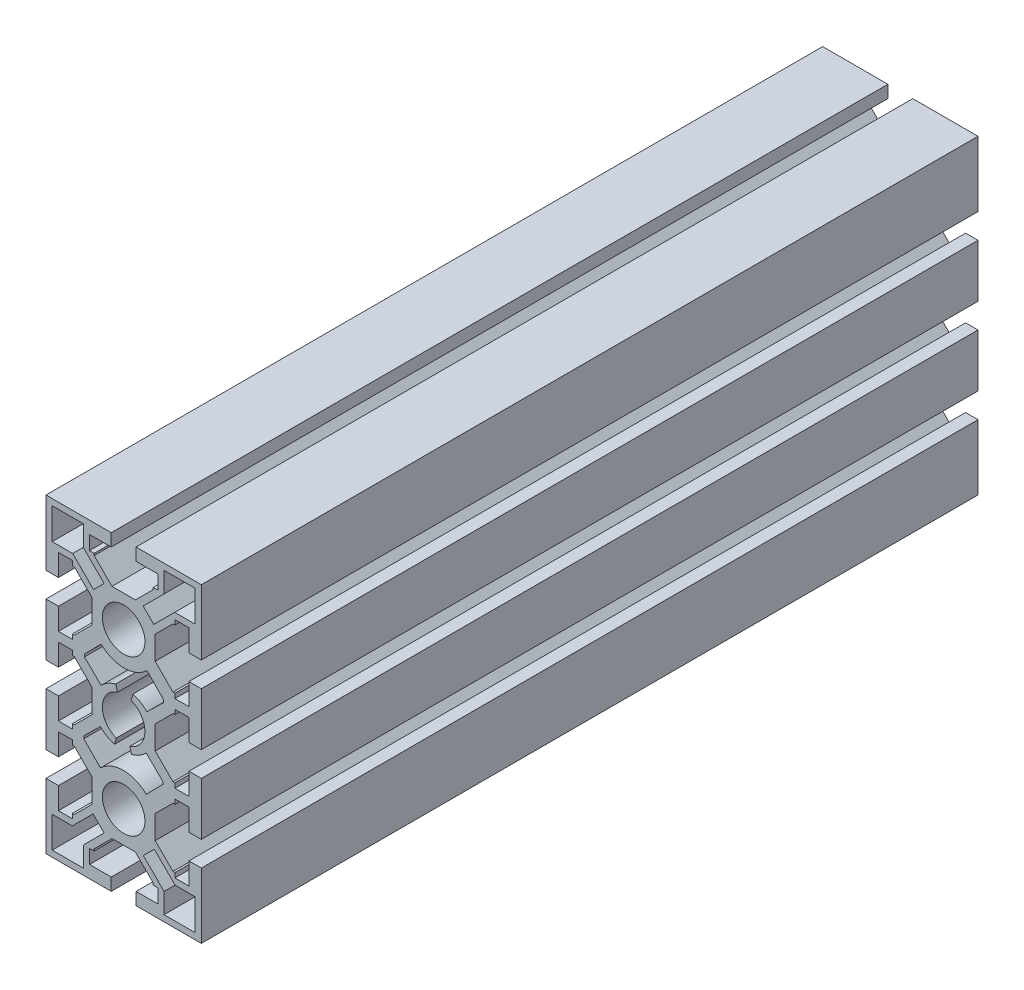
from build123d import *

# Parameters (mm, degrees)
SKETCH_A01_2_R     = 6.849979581
SKETCH_A01_2_R_2   = 6.85
SKETCH_A01_2_W     = 10
SKETCH_A01_2_H     = 10
EXTRUDE1_DEPTH     = 250
CUT_EXTRUDE1_DEPTH = 251
CIRPATTERN1_COUNT  = 2
CUT_EXTRUDE2_DEPTH = 251
CUT_EXTRUDE3_DEPTH = 251
CIRPATTERN2_COUNT  = 2
CIRPATTERN2_ANGLE  = 270
CIRPATTERN3_COUNT  = 2
CIRPATTERN3_ANGLE  = 90


with BuildPart() as part:
    # Sketch A01-2 → Extrude1 (new body)
    with BuildSketch(Plane.XY):
        Polygon((-16.5, -36), (-16.5, -34.5), (-15.863961, -34.5), (-10.14602885, -28.78206785), (-10.14602885, -21.21793215), (-15.863961, -15.5), (-16.5, -15.5), (-16.5, -14), (-21, -14), (-21, -21), (-25, -21), (-25, -4), (-21, -4), (-21, -11), (-16.5, -11), (-16.5, -9.5), (-15.863961, -9.5), (-10.14602885, -3.78206785), (-10.14602885, 3.78206785), (-15.863961, 9.5), (-16.5, 9.5), (-16.5, 11), (-21, 11), (-21, 4), (-25, 4), (-25, 21), (-21, 21), (-21, 14), (-16.5, 14), (-16.5, 15.5), (-15.863961, 15.5), (-10.14602885, 21.21793215), (-10.14602885, 28.78206785), (-15.863961, 34.5), (-16.5, 34.5), (-16.5, 36), (-21, 36), (-21, 29), (-25, 29), (-25, 50), (-4, 50), (-4, 46), (-11, 46), (-11, 41.5), (-9.5, 41.5), (-9.5, 40.863961), (-3.78206785, 35.14602885), (3.78206785, 35.14602885), (9.5, 40.863961), (9.5, 41.5), (11, 41.5), (11, 46), (4, 46), (4, 50), (25, 50), (25, 29), (21, 29), (21, 36), (16.5, 36), (16.5, 34.5), (15.863961, 34.5), (10.14602885, 28.78206785), (10.14602885, 21.21793215), (15.863961, 15.5), (16.5, 15.5), (16.5, 14), (21, 14), (21, 21), (25, 21), (25, 4), (21, 4), (21, 11), (16.5, 11), (16.5, 9.5), (15.863961, 9.5), (10.14602885, 3.78206785), (10.14602885, -3.78206785), (15.863961, -9.5), (16.5, -9.5), (16.5, -11), (21, -11), (21, -4), (25, -4), (25, -21), (21, -21), (21, -14), (16.5, -14), (16.5, -15.5), (15.863961, -15.5), (10.14602885, -21.21793215), (10.14602885, -28.78206785), (15.863961, -34.5), (16.5, -34.5), (16.5, -36), (21, -36), (21, -29), (25, -29), (25, -50), (4, -50), (4, -46), (11, -46), (11, -41.5), (9.5, -41.5), (9.5, -40.863961), (3.78206785, -35.14602885), (-3.78206785, -35.14602885), (-9.5, -40.863961), (-9.5, -41.5), (-11, -41.5), (-11, -46), (-4, -46), (-4, -50), (-25, -50), (-25, -29), (-21, -29), (-21, -36), align=None)
        Circle(SKETCH_A01_2_R, mode=Mode.SUBTRACT)
        with Locations((0, -25)):
            Circle(SKETCH_A01_2_R_2, mode=Mode.SUBTRACT)
        with Locations((0, 25)):
            Circle(SKETCH_A01_2_R, mode=Mode.SUBTRACT)
        with Locations((-18, -43)):
            Rectangle(SKETCH_A01_2_W, SKETCH_A01_2_H, mode=Mode.SUBTRACT)
        with Locations((18, -43)):
            Rectangle(SKETCH_A01_2_W, SKETCH_A01_2_H, mode=Mode.SUBTRACT)
        with Locations((-18, 43)):
            Rectangle(SKETCH_A01_2_W, SKETCH_A01_2_H, mode=Mode.SUBTRACT)
        with Locations((18, 43)):
            Rectangle(SKETCH_A01_2_W, SKETCH_A01_2_H, mode=Mode.SUBTRACT)
    extrude(amount=-EXTRUDE1_DEPTH)

    # Sketch1 → Cut-Extrude1 (cut, through all)
    with BuildSketch(Plane.XY):
        with BuildLine():
            Line((-7.258795353, 17.320361918), (-12.614234198, 11.855428431))
            Line((-12.614234198, 11.855428431), (-12.614234198, 11.051418253))
            Line((-12.614234198, 11.051418253), (-7.258795353, 5.803280231))
            ThreePointArc((-7.258795353, 5.803280231), (-5.094968204, 7.490334338), (-2.563122733, 8.547716957))
            Line((-2.563122733, 8.547716957), (-1.967487438, 6.56134235))
            ThreePointArc((-1.967487438, 6.56134235), (0.214842487, 6.846609596), (2.374993487, 6.425077913))
            Line((2.374993487, 6.425077913), (2.972164568, 8.497096186))
            ThreePointArc((2.972164568, 8.497096186), (5.403413421, 7.442330952), (7.485963159, 5.803280231))
            Line((7.485963159, 5.803280231), (12.841402004, 11.051418253))
            Line((12.841402004, 11.051418253), (12.841402004, 11.855428431))
            Line((12.841402004, 11.855428431), (7.485963159, 17.320361918))
            ThreePointArc((7.485963159, 17.320361918), (0.113583903, 14.310231562), (-7.258795353, 17.320361918))
        make_face()
    cut_extrude1 = extrude(amount=-CUT_EXTRUDE1_DEPTH, mode=Mode.SUBTRACT)

    # CirPattern1: Cut-Extrude1 ×2 about axis
    cirpattern1_axis = Axis((0, 0, 0), (0, 0, 1))
    for i in range(1, CIRPATTERN1_COUNT):
        add(cut_extrude1.rotate(cirpattern1_axis, i * 360 / CIRPATTERN1_COUNT), mode=Mode.SUBTRACT)

    # Sketch2 → Cut-Extrude2 (cut, through all)
    with BuildSketch(Plane.XY):
        Polygon((-16.419523035, 38), (-9.694317474, 31.274794439), (-6.274794439, 34.694317474), (-13, 41.419523035), align=None)
    cut_extrude2 = extrude(amount=-CUT_EXTRUDE2_DEPTH, mode=Mode.SUBTRACT)

    # Sketch3 → Cut-Extrude3 (cut, through all)
    with BuildSketch(Plane.XY):
        Polygon((-16.519090004, -38), (-9.847797296, -31.328707292), (-6.301034305, -34.875470283), (-13, -41.574435978), align=None)
    cut_extrude3 = extrude(amount=-CUT_EXTRUDE3_DEPTH, mode=Mode.SUBTRACT)

    # CirPattern2: Cut-Extrude2 ×2 about axis
    cirpattern2_axis = Axis((0, 25, 0), (0, 0, 1))
    for i in range(1, CIRPATTERN2_COUNT):
        add(cut_extrude2.rotate(cirpattern2_axis, i * CIRPATTERN2_ANGLE / (CIRPATTERN2_COUNT - 1)), mode=Mode.SUBTRACT)

    # CirPattern3: Cut-Extrude3 ×2 about axis
    cirpattern3_axis = Axis((0, -25, 0), (0, 0, 1))
    for i in range(1, CIRPATTERN3_COUNT):
        add(cut_extrude3.rotate(cirpattern3_axis, i * CIRPATTERN3_ANGLE / (CIRPATTERN3_COUNT - 1)), mode=Mode.SUBTRACT)


solid = part.part
